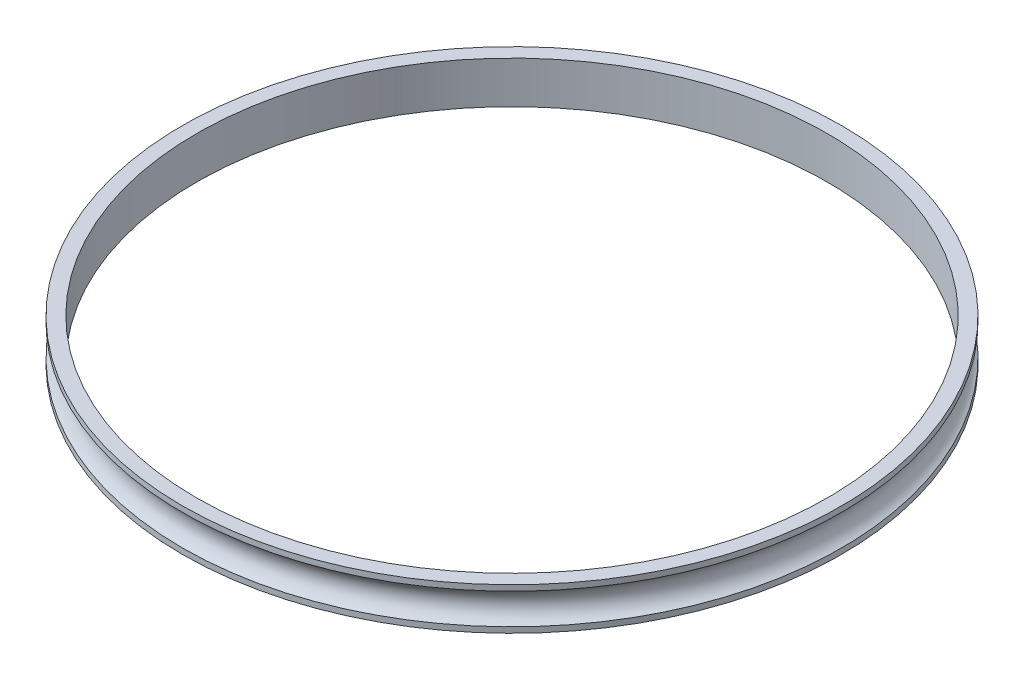
from build123d import *

# Parameters (mm, degrees)
SKETCH1_R           = 47
SKETCH1_R_2         = 45
BOSS_EXTRUDE1_DEPTH = 6
SKETCH4_R           = 2.5


with BuildPart() as part:
    # Sketch1 → Boss-Extrude1 (new body)
    with BuildSketch(Plane(origin=(0, 0, 0), x_dir=(1, 0, 0), z_dir=(0, 1, 0))):
        Circle(SKETCH1_R)
        Circle(SKETCH1_R_2, mode=Mode.SUBTRACT)
    extrude(amount=BOSS_EXTRUDE1_DEPTH)

    # Sketch4 → Cut-Revolve2 (revolve, cut)
    with BuildSketch(Plane(origin=(0, 0, 0), x_dir=(0, 0, -1), z_dir=(1, 0, 0))):
        with Locations((-48.2, 3)):
            Circle(SKETCH4_R)
    revolve(axis=Axis((0, 0, 0), (0, 1, 0)), mode=Mode.SUBTRACT)


solid = part.part
